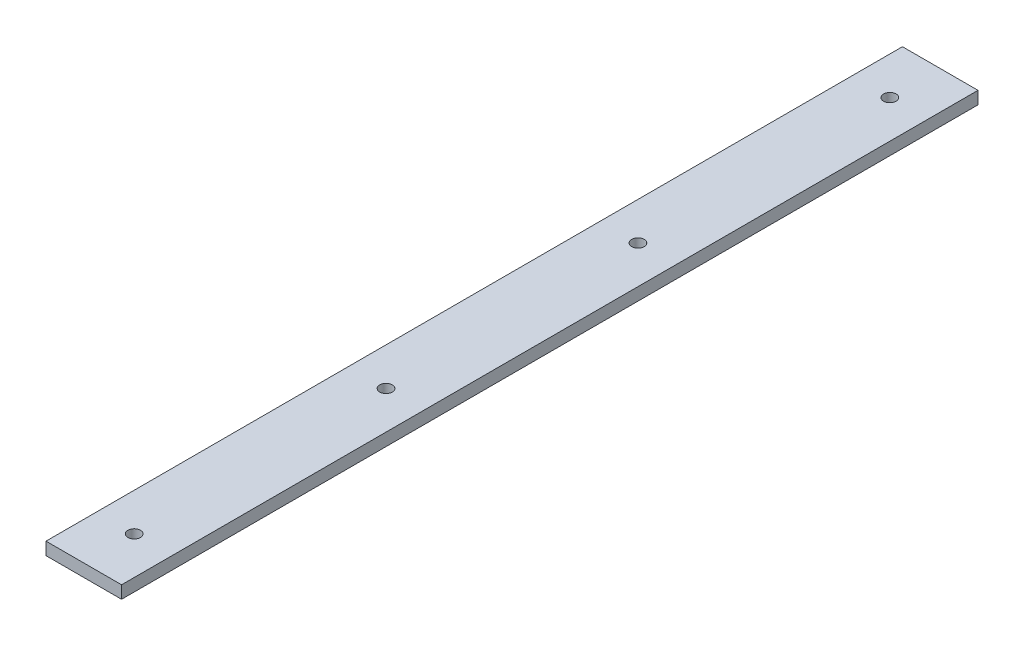
from build123d import *

# Parameters (mm, degrees)
SKETCH1_W           = 30
SKETCH1_H           = 5
BOSS_EXTRUDE1_DEPTH = 170
SKETCH3_R           = 2.5
CUT_EXTRUDE1_DEPTH  = 6


with BuildPart() as part:
    # Sketch1 → Boss-Extrude1 (new body, symmetric)
    with BuildSketch(Plane.XY):
        Rectangle(SKETCH1_W, SKETCH1_H)
    extrude(amount=BOSS_EXTRUDE1_DEPTH, both=True)

    # Sketch3 → Cut-Extrude1 (cut, through all)
    with BuildSketch(Plane(origin=(0, 2.5, 0), x_dir=(1, 0, 0), z_dir=(0, 1, 0))):
        with Locations((0, -50)):
            Circle(SKETCH3_R)
        with Locations((0, -150)):
            Circle(SKETCH3_R)
        with Locations((0, 150)):
            Circle(SKETCH3_R)
        with Locations((0, 50)):
            Circle(SKETCH3_R)
    extrude(amount=-CUT_EXTRUDE1_DEPTH, mode=Mode.SUBTRACT)


solid = part.part
